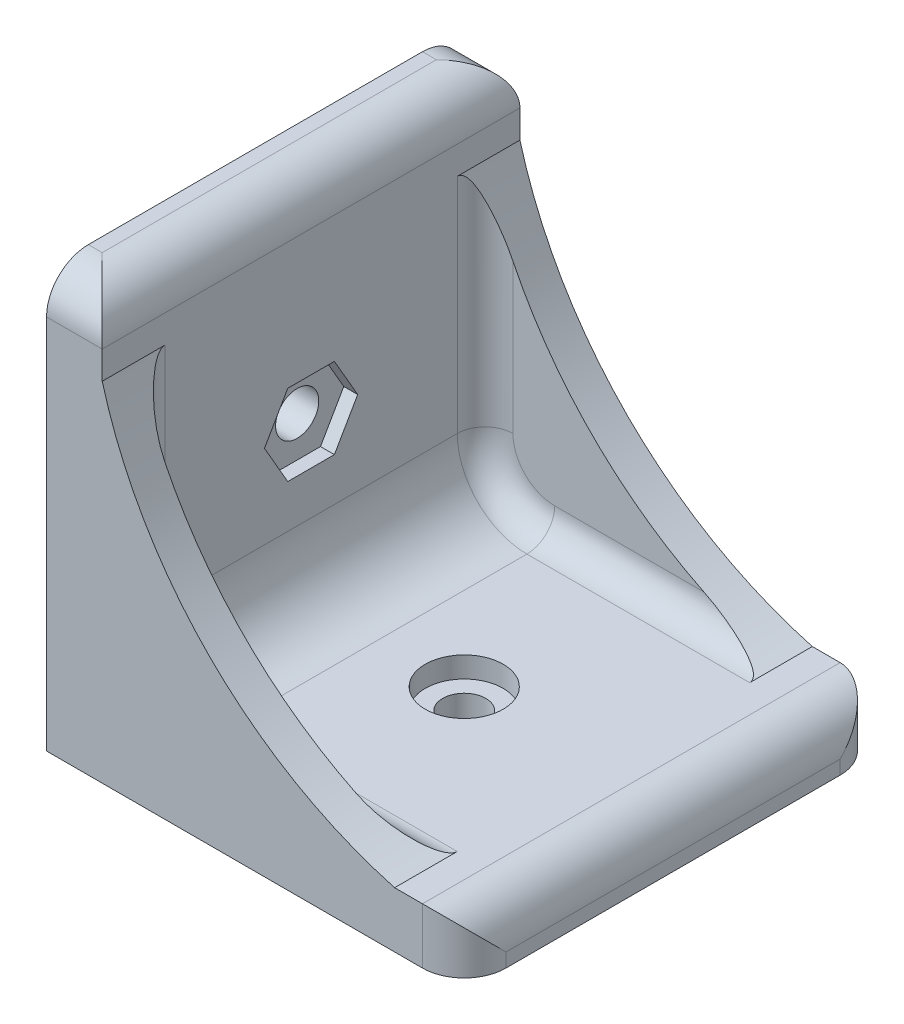
from build123d import *

# Parameters (mm, degrees)
CROQUIS1_W              = 30
CROQUIS1_H              = 30
SALIENTE_EXTRUIR1_DEPTH = 30
CROQUIS2_W              = 26
CROQUIS2_H              = 30
CORTAR_EXTRUIR1_DEPTH   = 26
CROQUIS3_R              = 1.55
CORTAR_EXTRUIR2_DEPTH   = 4
CROQUIS4_R              = 1.55
CORTAR_EXTRUIR3_DEPTH   = 4
CORTAR_EXTRUIR5_DEPTH   = 1
SALIENTE_EXTRUIR2_DEPTH = 2.5
SALIENTE_EXTRUIR3_DEPTH = 2.5
CROQUIS9_R              = 2.8
CORTAR_EXTRUIR6_DEPTH   = 1.5
REDONDEO1_R             = 5
REDONDEO2_R             = 3
REDONDEO3_R             = 2


with BuildPart() as part:
    # Croquis1 → Saliente-Extruir1 (new body)
    with BuildSketch(Plane(origin=(0, 0, 0), x_dir=(1, 0, 0), z_dir=(0, 1, 0))):
        with Locations((15, 15)):
            Rectangle(CROQUIS1_W, CROQUIS1_H)
    extrude(amount=SALIENTE_EXTRUIR1_DEPTH)

    # Croquis2 → Cortar-Extruir1 (cut)
    with BuildSketch(Plane(origin=(0, 30, 0), x_dir=(1, 0, 0), z_dir=(0, 1, 0))):
        with Locations((17, 15)):
            Rectangle(CROQUIS2_W, CROQUIS2_H)
    extrude(amount=-CORTAR_EXTRUIR1_DEPTH, mode=Mode.SUBTRACT)

    # Croquis3 → Cortar-Extruir2 (cut)
    with BuildSketch(Plane(origin=(4, 0, 0), x_dir=(0, 0, -1), z_dir=(1, 0, 0))):
        with Locations((15, 15)):
            Circle(CROQUIS3_R)
    extrude(amount=-CORTAR_EXTRUIR2_DEPTH, mode=Mode.SUBTRACT)

    # Croquis4 → Cortar-Extruir3 (cut)
    with BuildSketch(Plane(origin=(0, 4, 0), x_dir=(1, 0, 0), z_dir=(0, 1, 0))):
        with Locations((15, 15)):
            Circle(CROQUIS4_R)
    extrude(amount=-CORTAR_EXTRUIR3_DEPTH, mode=Mode.SUBTRACT)

    # Croquis6 → Cortar-Extruir5 (cut)
    with BuildSketch(Plane(origin=(4, 0, 0), x_dir=(0, 0, -1), z_dir=(1, 0, 0))):
        Polygon((11.651368439, 15), (13.325684219, 12.1), (16.674315781, 12.1), (18.348631561, 15), (16.674315781, 17.9), (13.325684219, 17.9), align=None)
    extrude(amount=-CORTAR_EXTRUIR5_DEPTH, mode=Mode.SUBTRACT)

    # Croquis7 → Saliente-Extruir2 (add)
    with BuildSketch(Plane.XY):
        with BuildLine():
            Line((25, 4), (4, 4))
            Line((4, 4), (4, 25))
            ThreePointArc((4, 25), (11.719105156, 11.719105156), (25, 4))
        make_face()
    extrude(amount=-SALIENTE_EXTRUIR2_DEPTH)

    # Croquis8 → Saliente-Extruir3 (add)
    with BuildSketch(Plane(origin=(0, 0, -30), x_dir=(-1, 0, 0), z_dir=(0, 0, -1))):
        with BuildLine():
            Line((-25, 4), (-4, 4))
            Line((-4, 4), (-4, 25))
            ThreePointArc((-4, 25), (-11.719105156, 11.719105156), (-25, 4))
        make_face()
    extrude(amount=-SALIENTE_EXTRUIR3_DEPTH)

    # Croquis9 → Cortar-Extruir6 (cut)
    with BuildSketch(Plane(origin=(0, 4, 0), x_dir=(1, 0, 0), z_dir=(0, 1, 0))):
        with Locations((15, 15)):
            Circle(CROQUIS9_R)
    extrude(amount=-CORTAR_EXTRUIR6_DEPTH, mode=Mode.SUBTRACT)

    # Redondeo1
    redondeo1_edges = [part.edges().sort_by_distance(p)[0] for p in [
        (4, 4, -15),
    ]]
    fillet(redondeo1_edges, radius=REDONDEO1_R)

    # Redondeo2
    redondeo2_edges = [part.edges().sort_by_distance(p)[0] for p in [
        (2, 30, -30),
        (30, 2, -30),
        (30, 2, 0),
        (30, 4, -15),
        (4, 30, -15),
        (2, 30, 0),
    ]]
    fillet(redondeo2_edges, radius=REDONDEO2_R)

    # Redondeo3
    redondeo3_edges = [part.edges().sort_by_distance(p)[0] for p in [
        (4, 17, -2.5),
        (17, 4, -27.5),
        (17, 4, -2.5),
        (5.464466094, 5.464466094, -2.5),
        (4, 17, -27.5),
        (5.464466094, 5.464466094, -27.5),
    ]]
    fillet(redondeo3_edges, radius=REDONDEO3_R)


solid = part.part
